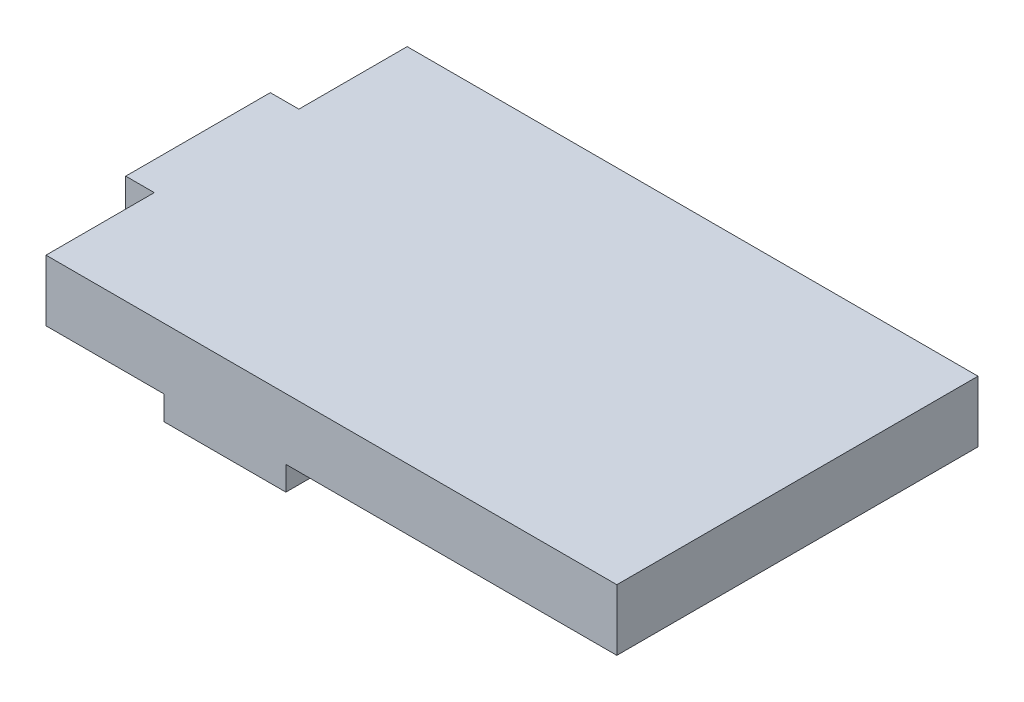
from build123d import *

# Parameters (mm, degrees)
BOSS_EXTRUDE1_DEPTH     = 5.08
SKETCH2_W               = 10.11
SKETCH2_H               = 4.63
BOSS_EXTRUDE2_DEPTH     = 2
CUT_EXTRUDE1_DEPTH      = 50.943950955
CUT_EXTRUDE1_DEPTH_BACK = 50.943950955
SKETCH3_W               = 16.045
SKETCH3_H               = 12


with BuildPart() as part:
    # Sketch1 → Boss-Extrude1 (new body)
    with BuildSketch(Plane(origin=(0, 0, 0), x_dir=(1, 0, 0), z_dir=(0, 1, 0))):
        Polygon((0, -6), (0, -14.986), (47.371, -14.986), (47.371, 14.986), (0, 14.986), (0, 6), (-18.415, 6), (-18.415, -6), align=None)
    extrude(amount=BOSS_EXTRUDE1_DEPTH)

    # Sketch2 → Boss-Extrude2 (add)
    with BuildSketch(Plane(origin=(0, 0, 0), x_dir=(1, 0, 0), z_dir=(0, 1, 0))):
        with Locations((14.855, -12.671)):
            Rectangle(SKETCH2_W, SKETCH2_H)
    extrude(amount=-BOSS_EXTRUDE2_DEPTH)

    # Sketch3 → Cut-Extrude1 (cut, two sides: drawn at the far end of the back side and taken through both)
    with BuildSketch(Plane(origin=(0, 0, 0), x_dir=(1, 0, 0), z_dir=(0, 1, 0)).offset(-CUT_EXTRUDE1_DEPTH_BACK)):
        with Locations((-10.3925, 0)):
            Rectangle(SKETCH3_W, SKETCH3_H)
    extrude(amount=CUT_EXTRUDE1_DEPTH + CUT_EXTRUDE1_DEPTH_BACK, mode=Mode.SUBTRACT)


solid = part.part
